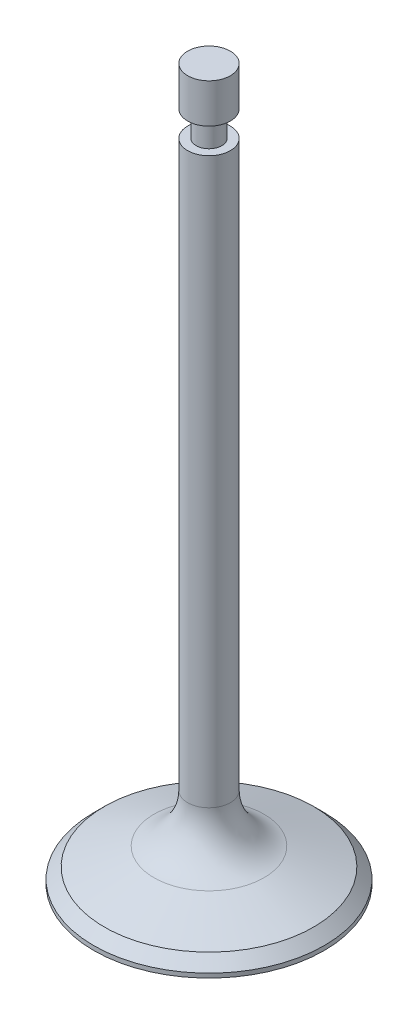
from build123d import *


with BuildPart() as part:
    # Sketch1 → Revolve1 (revolve)
    with BuildSketch(Plane.XY):
        with BuildLine():
            Line((0, 0), (0, 84.495))
            Line((0, 84.495), (2.5, 84.495))
            Line((2.5, 84.495), (2.5, 79.895))
            Line((2.5, 79.895), (1.5, 79.895))
            Line((1.5, 79.895), (1.5, 76.895))
            Line((1.5, 76.895), (2.5, 76.895))
            Line((2.5, 76.895), (2.5, 10.749955013))
            ThreePointArc((2.5, 10.749955013), (3.585087734, 7.308496395), (6.44787914, 5.111799289))
            Line((6.44787914, 5.111799289), (12.25, 3))
            Line((12.25, 3), (13.5, 1.75))
            Line((13.5, 1.75), (13.5, 1.25))
            ThreePointArc((13.5, 1.25), (6.778873431, 0.31316694), (0, 0))
        make_face()
    revolve(axis=Axis((0, 0, 0), (0, 1, 0)))


solid = part.part
